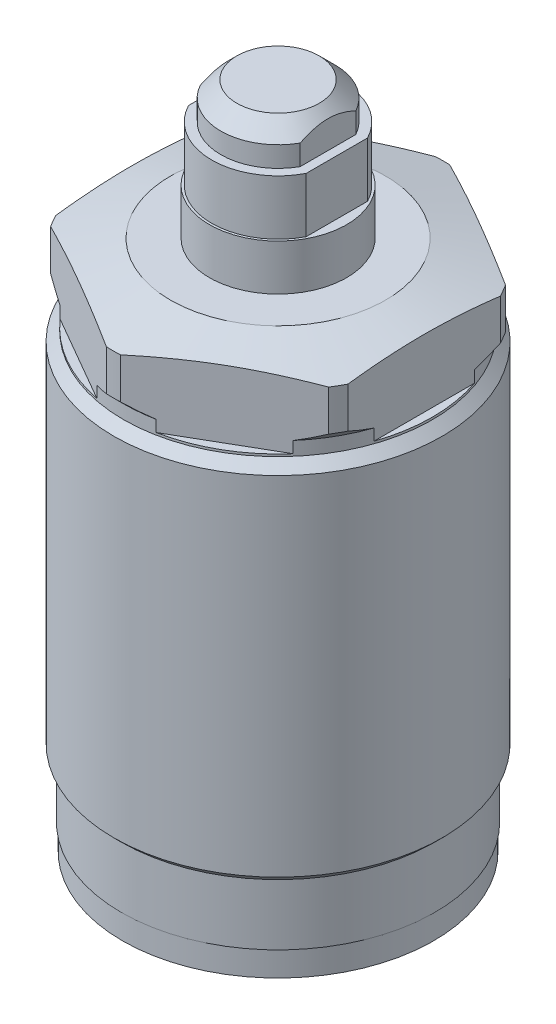
from build123d import *

# Parameters (mm, degrees)
SKETCH2_OUTSIDE_W       = 53.436
SKETCH2_OUTSIDE_H       = 53.436
CUT_EXTRUDE1_DEPTH      = 8.5
CHAMFER1_SIZE           = 1.754
SKETCH5_W               = 1.79
SKETCH5_H               = 3.988
CUT_EXTRUDE2_DEPTH      = 19
CUT_EXTRUDE2_DEPTH_BACK = 19
SKETCH6_W               = 1.075
SKETCH6_H               = 5.994
CUT_EXTRUDE3_DEPTH      = 19
CUT_EXTRUDE3_DEPTH_BACK = 19


with BuildPart() as part:
    # Sketch1 → Revolve1 (revolve)
    with BuildSketch(Plane.XY, mode=Mode.PRIVATE) as revolve1_sk:
        Polygon((-17.125, 0), (-17, 0), (-17, -2.75), (0, -2.75), (0, 55.25), (-11.75, 55.25), (-18, 53.575317547), (-18, 49.125), (-16.875, 48), (-16.875, 46.5), (-17.925, 45.45), (-17.925, 7.45), (-17.125, 6.65), align=None)
    revolve(revolve1_sk.sketch.rotate(Axis((0, 0, 0), (0, -1, 0)), 270), axis=Axis((0, 0, 0), (0, -1, 0)))  # turned: the seam where the file's is

    # Sketch2 outside → Cut-Extrude1 (cut)
    with BuildSketch(Plane(origin=(0, 55.25, 0), x_dir=(1, 0, 0), z_dir=(0, 1, 0))):
        Rectangle(SKETCH2_OUTSIDE_W, SKETCH2_OUTSIDE_H)
        Polygon((0, 18.429020593), (-15.96, 9.214510296), (-15.96, -9.214510296), (0, -18.429020593), (15.96, -9.214510296), (15.96, 9.214510296), align=None, mode=Mode.SUBTRACT)
    extrude(amount=-CUT_EXTRUDE1_DEPTH, mode=Mode.SUBTRACT)

    # Sketch4 → Revolve2 (revolve)
    with BuildSketch(Plane.XY, mode=Mode.PRIVATE) as revolve2_sk:
        Polygon((0, 70.25), (-6.25, 70.25), (-6.25, 66.262), (-7.25, 66.262), (-7.25, 60.268), (-7.5, 60.268), (-7.5, 55.25), (0, 55.25), align=None)
    revolve(revolve2_sk.sketch.rotate(Axis((0, 0, 0), (0, 1, 0)), 90), axis=Axis((0, 0, 0), (0, 1, 0)))  # turned: the seam where the file's is

    # Chamfer1
    chamfer1_edges = [part.edges().sort_by_distance(p)[0] for p in [
        (0, 70.25, -6.25),
    ]]
    chamfer(chamfer1_edges, length=CHAMFER1_SIZE)

    # Sketch5 → Cut-Extrude2 (cut, two sides)
    with BuildSketch(Plane.XY) as cut_extrude2_sk:
        with Locations((-6.355, 68.256)):
            Rectangle(SKETCH5_W, SKETCH5_H)
        with Locations((6.355, 68.256)):
            Rectangle(SKETCH5_W, SKETCH5_H)
    extrude(amount=CUT_EXTRUDE2_DEPTH, mode=Mode.SUBTRACT)
    extrude(cut_extrude2_sk.sketch, amount=-CUT_EXTRUDE2_DEPTH_BACK, mode=Mode.SUBTRACT)

    # Sketch6 → Cut-Extrude3 (cut, two sides)
    with BuildSketch(Plane.XY) as cut_extrude3_sk:
        with Locations((-6.9625, 63.265)):
            Rectangle(SKETCH6_W, SKETCH6_H)
        with Locations((6.9625, 63.265)):
            Rectangle(SKETCH6_W, SKETCH6_H)
    extrude(amount=CUT_EXTRUDE3_DEPTH, mode=Mode.SUBTRACT)
    extrude(cut_extrude3_sk.sketch, amount=-CUT_EXTRUDE3_DEPTH_BACK, mode=Mode.SUBTRACT)


solid = part.part
